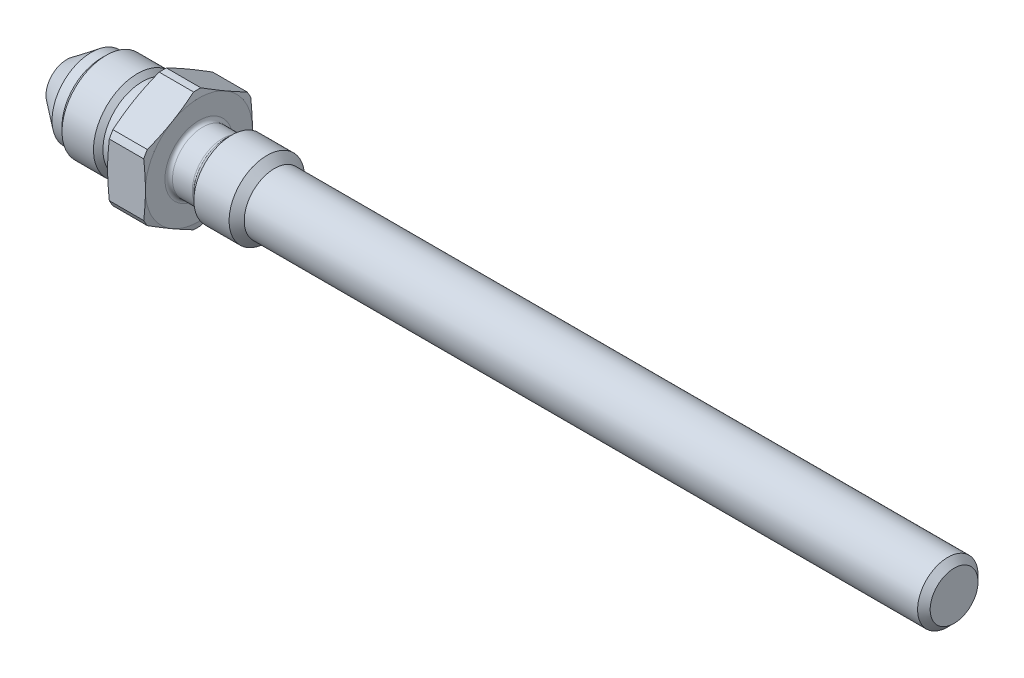
from build123d import *

# Parameters (mm, degrees)
SKETCH_2_OUTSIDE_W  = 49.708
SKETCH_2_OUTSIDE_H  = 49.708
CUT_EXTRUDE_1_DEPTH = 127
CHAMFER_1_SIZE      = 1
FILLET_1_R          = 0.6


with BuildPart() as part:
    # Эскиз1 → Повернуть1 (revolve)
    with BuildSketch(Plane.XY):
        Polygon((0, 8.5), (0, 4.8), (4, 4.8), (5.2, 6), (10.8, 6), (12, 4.8), (120, 4.8), (120, 0), (115.802581857, 0), (114, 3), (-21, 3), (-21, 3.3), (-17.085217776, 6.25), (-15.5, 6.25), (-14.75, 7), (-9.75, 7), (-9, 6.25), (-6, 6.25), (-6, 8.5), (-5.732050808, 9.5), (-0.267949192, 9.5), align=None)
    revolve(axis=Axis((0, 0, 0), (-1, 0, 0)))

    # Эскиз2 outside → Вырез-Вытянуть1 (cut, through all)
    with BuildSketch(Plane.ZY.offset(6)):
        Rectangle(SKETCH_2_OUTSIDE_W, SKETCH_2_OUTSIDE_H)
        Polygon((0, 9.814954576), (-8.5, 4.907477288), (-8.5, -4.907477288), (0, -9.814954576), (8.5, -4.907477288), (8.5, 4.907477288), align=None, mode=Mode.SUBTRACT)
    extrude(amount=-CUT_EXTRUDE_1_DEPTH, mode=Mode.SUBTRACT)

    # Фаска1
    chamfer_1_edges = [part.edges().sort_by_distance(p)[0] for p in [
        (120, -4.8, 0),
    ]]
    chamfer(chamfer_1_edges, length=CHAMFER_1_SIZE)

    # Скругление1
    fillet_1_edges = [part.edges().sort_by_distance(p)[0] for p in [
        (4, -4.8, 0),
        (0, -4.8, 0),
    ]]
    fillet(fillet_1_edges, radius=FILLET_1_R)


solid = part.part
